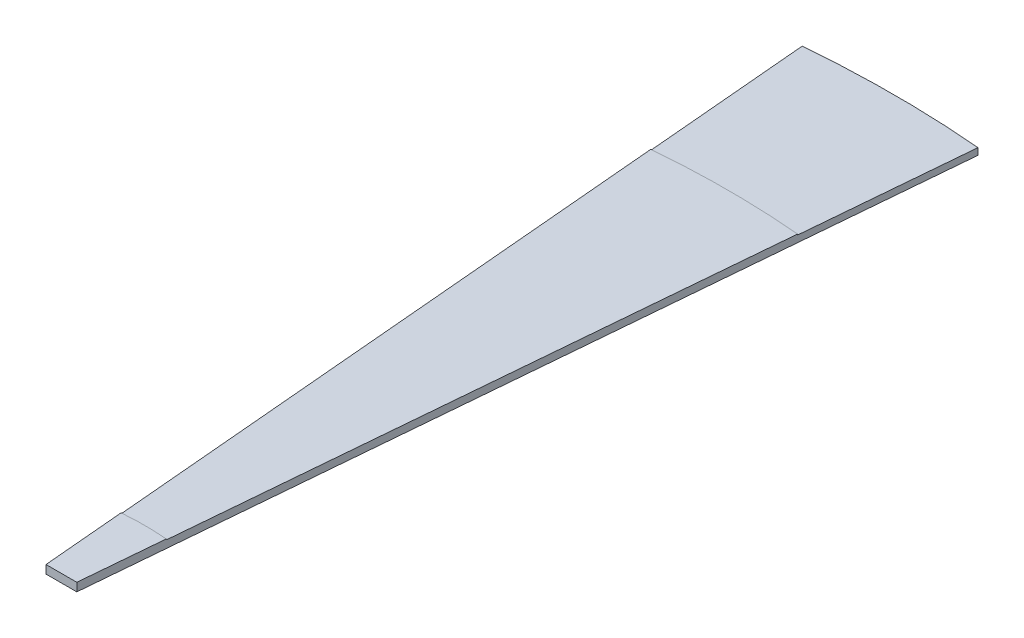
from build123d import *

# Parameters (mm, degrees)
EXTRUSION1_DEPTH = 10
EXTRUSION2_DEPTH = 9
EXTRUSION3_DEPTH = 8


with BuildPart() as part:
    # Esquisse1 → Extrusion1 (new body)
    with BuildSketch(Plane(origin=(0, 0, 0), x_dir=(1, 0, 0), z_dir=(0, 1, 0))):
        with BuildLine():
            Line((18.5, 0), (-18.5, 0))
            Line((-18.5, 0), (-27.145176189, 98.814816012))
            ThreePointArc((-27.145176189, 98.814816012), (0, 100), (27.145176189, 98.814816012))
            Line((27.145176189, 98.814816012), (18.5, 0))
        make_face()
    extrude(amount=EXTRUSION1_DEPTH)

    # Esquisse2 → Extrusion2 (add)
    with BuildSketch(Plane.XZ):
        with BuildLine():
            Line((-27.145176189, -98.814816012), (-88.154196113, -796.151104676))
            ThreePointArc((-88.154196113, -796.151104676), (0, -800), (88.154196113, -796.151104676))
            Line((88.154196113, -796.151104676), (27.145176189, -98.814816012))
            ThreePointArc((27.145176189, -98.814816012), (0, -100), (-27.145176189, -98.814816012))
        make_face()
    extrude(amount=-EXTRUSION2_DEPTH)

    # Esquisse5 → Extrusion3 (add)
    with BuildSketch(Plane.XZ):
        with BuildLine():
            Line((-88.154196113, -796.151104676), (-105.585344662, -995.390044295))
            ThreePointArc((-105.585344662, -995.390044295), (0, -1000), (105.585344662, -995.390044295))
            Line((105.585344662, -995.390044295), (88.154196113, -796.151104676))
            ThreePointArc((88.154196113, -796.151104676), (0, -800), (-88.154196113, -796.151104676))
        make_face()
    extrude(amount=-EXTRUSION3_DEPTH)


solid = part.part
